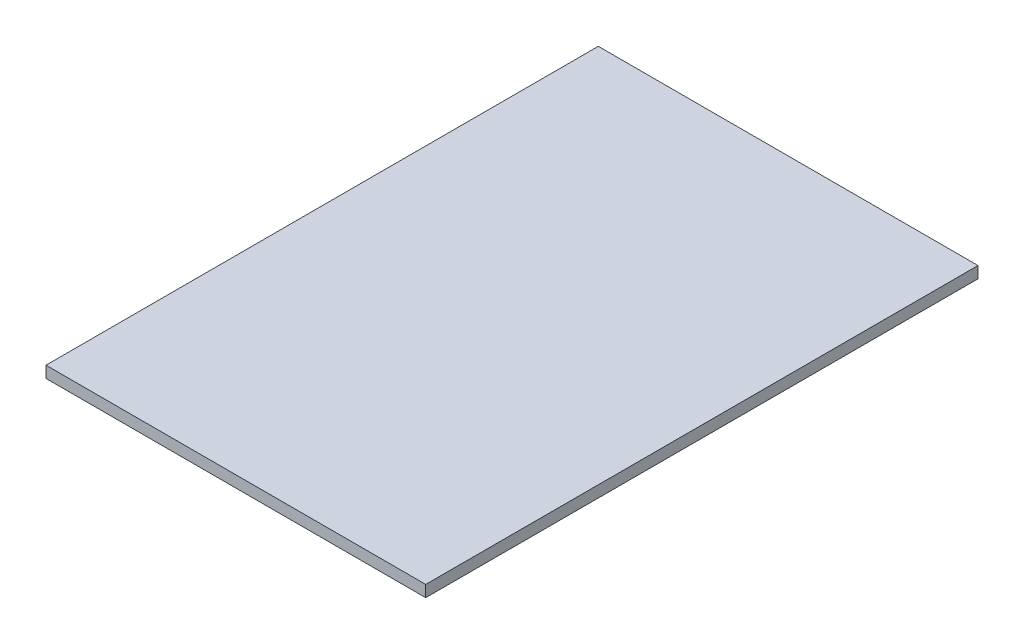
from build123d import *

# Parameters (mm, degrees)
SKETCH2_W           = 66
SKETCH2_H           = 96
BOSS_EXTRUDE1_DEPTH = 2


with BuildPart() as part:
    # Sketch2 → Boss-Extrude1 (new body)
    with BuildSketch(Plane(origin=(0, 0, 0), x_dir=(1, 0, 0), z_dir=(0, 1, 0))):
        Rectangle(SKETCH2_W, SKETCH2_H)
    extrude(amount=BOSS_EXTRUDE1_DEPTH)


solid = part.part
